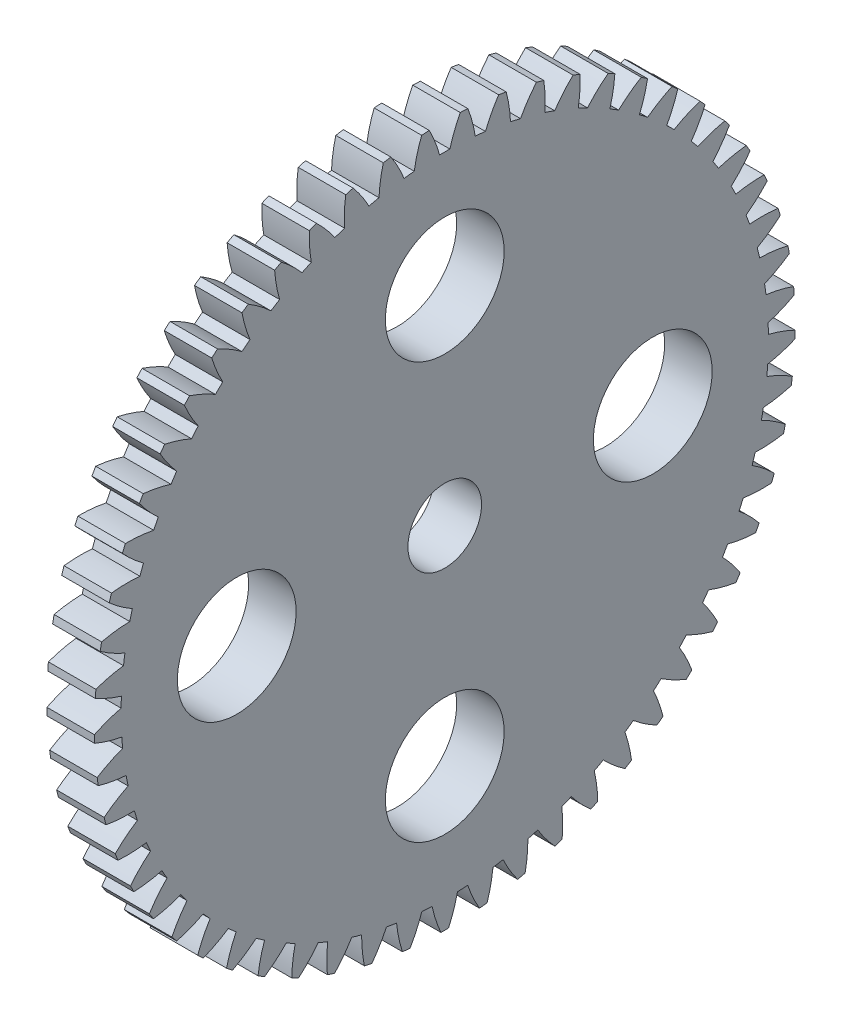
from build123d import *

# Parameters (mm, degrees)
BASPROSKE_W        = 4
BASPROSKE_H        = 29.5
TOOTHCUT_DEPTH     = 42.910619179
TEETHCUTS_COUNT    = 57
TEETHCUTS_ANGLE    = 353.684210526
BORSKE_R           = 3.1
BORE_DEPTH         = 50.0000508
SKETCH1_R          = 5
CUT_EXTRUDE1_DEPTH = 10


with BuildPart() as part:
    # BasProSke → Base-Revolve (revolve)
    with BuildSketch(Plane(origin=(0, 0, 0), x_dir=(1, 0, 0), z_dir=(0, 1, 0)), mode=Mode.PRIVATE) as base_revolve_sk:
        with Locations((2, 14.75)):
            Rectangle(BASPROSKE_W, BASPROSKE_H)
    revolve(base_revolve_sk.sketch.rotate(Axis((-10, 0, 0), (1, 0, 0)), 180), axis=Axis((-10, 0, 0), (1, 0, 0)))

    # TooCutSke → ToothCut (cut, through all)
    with BuildSketch(Plane(origin=(0, 0, 0), x_dir=(0, 0, -1), z_dir=(1, 0, 0))):
        with BuildLine():
            ThreePointArc((0.432142545, 27.245573105), (0, 27.249), (-0.432142545, 27.245573105))
            ThreePointArc((-0.432142545, 27.245573105), (-0.814773323, 28.394321615), (-1.317082666, 29.496008856))
            ThreePointArc((-1.317082666, 29.496008856), (0, 29.5254), (1.317082666, 29.496008856))
            ThreePointArc((1.317082666, 29.496008856), (0.814773323, 28.394321615), (0.432142545, 27.245573105))
        make_face()
    toothcut = extrude(amount=TOOTHCUT_DEPTH, mode=Mode.SUBTRACT)

    # TeethCuts: ToothCut ×57 about axis
    teethcuts_axis = Axis((-10, 0, 0), (1, 0, 0))
    for i in range(1, TEETHCUTS_COUNT):
        add(toothcut.rotate(teethcuts_axis, i * TEETHCUTS_ANGLE / (TEETHCUTS_COUNT - 1)), mode=Mode.SUBTRACT)

    # BorSke → Bore (cut, symmetric)
    with BuildSketch(Plane(origin=(0, 0, 0), x_dir=(0, 0, -1), z_dir=(1, 0, 0))):
        with Locations(Location((0, 0, 0), (0, 0, 180))):
            Circle(BORSKE_R)
    extrude(amount=BORE_DEPTH, both=True, mode=Mode.SUBTRACT)

    # Sketch1 → Cut-Extrude1 (cut)
    with BuildSketch(Plane(origin=(4, 0, 0), x_dir=(0, 0, -1), z_dir=(1, 0, 0))):
        with Locations((0, -17.513416598)):
            Circle(SKETCH1_R)
        with Locations((-17.513416598, 0)):
            Circle(SKETCH1_R)
        with Locations((0, 17.513416598)):
            Circle(SKETCH1_R)
        with Locations((17.513416598, 0)):
            Circle(SKETCH1_R)
    extrude(amount=-CUT_EXTRUDE1_DEPTH, mode=Mode.SUBTRACT)


solid = part.part
